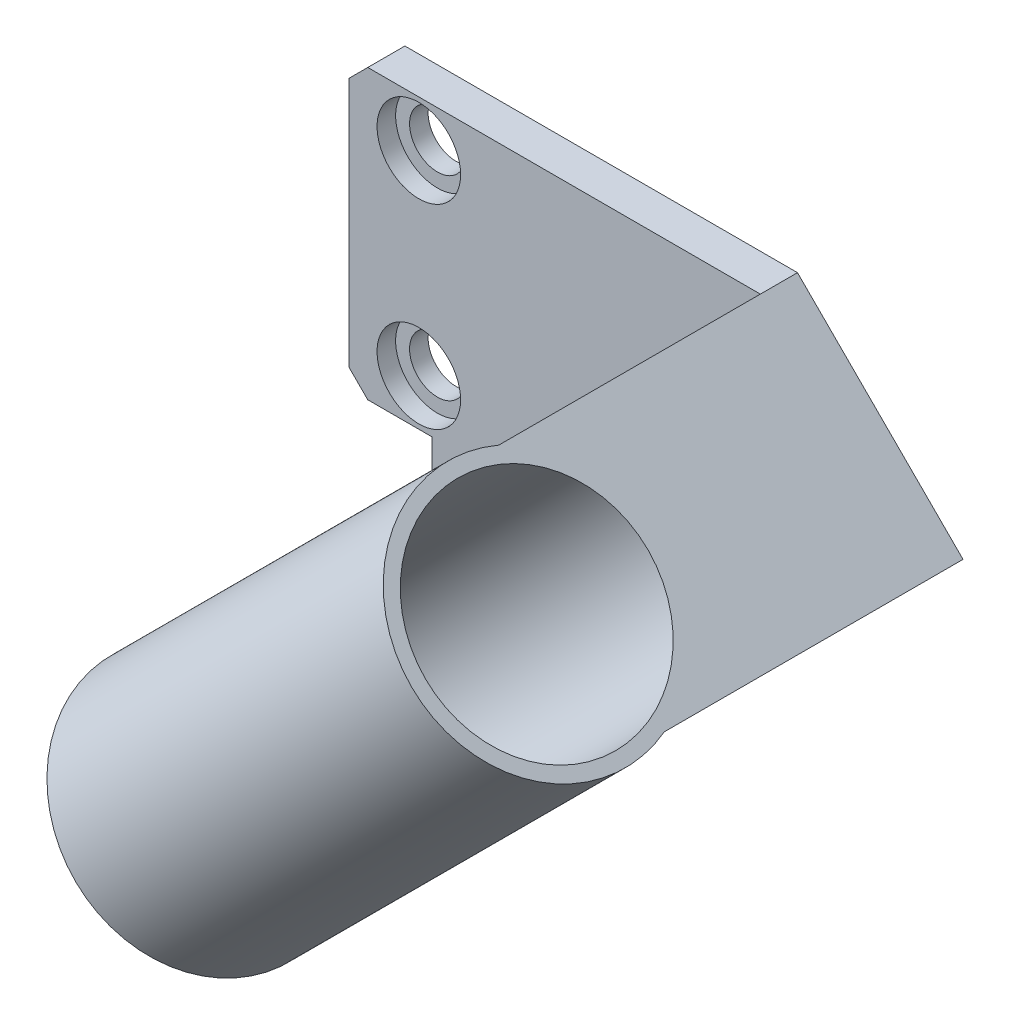
from build123d import *

# Parameters (mm, degrees)
SKETCH1_W                = 15
SKETCH1_H                = 31
SKETCH1_R                = 3
BOSS_EXTRUDE1_DEPTH      = 4
SKETCH2_R                = 4.5
CUT_EXTRUDE1_DEPTH       = 2
CHAMFER1_SIZE            = 2
BOSS_EXTRUDE3_DEPTH      = 4
SKETCH4_R                = 13.5
SKETCH4_R_2              = 12
BOSS_EXTRUDE4_DEPTH      = 51.220242393
BOSS_EXTRUDE5_REACH      = 79.695
BOSS_EXTRUDE5_END_RADIUS = 13.5


with BuildPart() as part:
    # Sketch1 → Boss-Extrude1 (new body)
    with BuildSketch(Plane.XY):
        with Locations((0, 10.5)):
            Rectangle(SKETCH1_W, SKETCH1_H)
        Circle(SKETCH1_R, mode=Mode.SUBTRACT)
        with Locations((0, 21)):
            Circle(SKETCH1_R, mode=Mode.SUBTRACT)
    extrude(amount=BOSS_EXTRUDE1_DEPTH)

    # Sketch2 → Cut-Extrude1 (cut)
    with BuildSketch(Plane.XY.offset(4)):
        with Locations((0, 21)):
            Circle(SKETCH2_R)
        Circle(SKETCH2_R)
    extrude(amount=-CUT_EXTRUDE1_DEPTH, mode=Mode.SUBTRACT)

    # Chamfer1
    chamfer1_edges = [part.edges().sort_by_distance(p)[0] for p in [
        (-7.5, -5, 2),
        (-7.5, 26, 2),
    ]]
    chamfer(chamfer1_edges, length=CHAMFER1_SIZE)

    # Sketch3 → Boss-Extrude3 (add)
    with BuildSketch(Plane.XY.offset(4)):
        Polygon((1.423063068, -5), (7.5, -5), (7.5, 26), (36.782487596, 26), (54.611806547, 8.17068105), (41.441125497, -5), (18.393625817, -28.04749968), (1.423063068, -11.076936932), align=None)
    extrude(amount=-BOSS_EXTRUDE3_DEPTH)



with BuildPart() as body_2:
    # Sketch4 → Boss-Extrude4 (new body)
    with BuildSketch(Plane(origin=(31.391243798, 31.391243798, 0), x_dir=(0, 0, -1), z_dir=(0.7071067811865465, 0.7071067811865487, 0))):
        with Locations(Location((-37, -20.231602431, 0), (0, 0, 90))):
            Circle(SKETCH4_R)
        with Locations(Location((-37, -20.231602431, 0), (0, 0, 90))):
            Circle(SKETCH4_R_2, mode=Mode.SUBTRACT)
    extrude(amount=-BOSS_EXTRUDE4_DEPTH)


with BuildPart() as part_1:
    add(part.part)

    add(body_2.part)  # Boss-Extrude5 merges body 2
    # Boss-Extrude5: up to this cylinder (the profile starts outside it)
    boss_extrude5_end = Plane(origin=(27.737015773, -0.874790773, 37), z_dir=(0.7071067811865465, 0.7071067811865487, 0)) * Cylinder(BOSS_EXTRUDE5_END_RADIUS, 187.39, mode=Mode.PRIVATE)
    # Sketch5 → Boss-Extrude5 (add, up to the surface)
    with BuildSketch(Plane.XY.offset(4), mode=Mode.PRIVATE) as boss_extrude5_sk1:
        Polygon((1.423063068, -11.076936932), (36.782487596, 26), (54.611806547, 8.17068105), (18.393625817, -28.04749968), align=None)
    boss_extrude5_tool1 = extrude(boss_extrude5_sk1.sketch, amount=BOSS_EXTRUDE5_REACH, mode=Mode.PRIVATE) - boss_extrude5_end
    add(boss_extrude5_tool1.solids().sort_by_distance((27.949939, -1.087714, 4))[0])


solid = part_1.part
